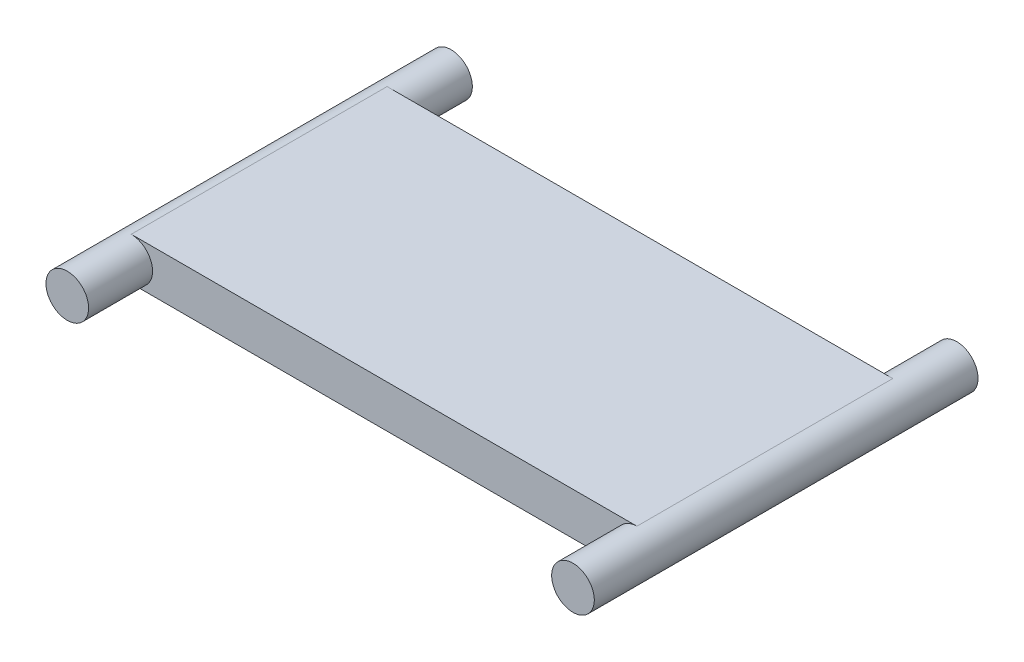
from build123d import *
from build123d.topology import SkipClean

# Parameters (mm, degrees)
BOSS_EXTRUDE1_DEPTH     = 9.525
SKETCH3_R               = 1.5875
BOSS_EXTRUDE3_DEPTH     = 4.7625
MIRROR2_COPY_1_SKETCH_R = 1.5875
MIRROR2_COPY_1_DEPTH    = 4.7625


with BuildPart() as part:
    # Sketch1 → Boss-Extrude1 (new body, symmetric)
    with BuildSketch(Plane.XY):
        with BuildLine():
            Line((-18.82775, 1.5875), (18.82775, 1.5875))
            ThreePointArc((18.82775, 1.5875), (20.41525, 0), (18.82775, -1.5875))
            Line((18.82775, -1.5875), (-18.82775, -1.5875))
            ThreePointArc((-18.82775, -1.5875), (-20.41525, 0), (-18.82775, 1.5875))
        make_face()
    extrude(amount=BOSS_EXTRUDE1_DEPTH, both=True)

    # Sketch3 → Boss-Extrude3 (add)
    with BuildSketch(Plane.XY.offset(9.525)):
        with Locations(Location((-18.82775, 0, 0), (0, 0, 270))):  # turned: the seam where the file's is
            Circle(SKETCH3_R)
    boss_extrude3 = extrude(amount=BOSS_EXTRUDE3_DEPTH)

    # Mirror1: Boss-Extrude3 across plane
    with SkipClean():  # keep this step's faces unmerged: merging them makes the solid invalid here
        add(boss_extrude3.mirror(Plane(origin=(0, 0, 0), x_dir=(0, 0, 1), z_dir=(1, 0, 0))))

    # Mirror2: Boss-Extrude3 across plane
    with SkipClean():  # keep this step's faces unmerged: merging them makes the solid invalid here
        add(boss_extrude3.mirror(Plane.XY))

    # Mirror2 copy 1 sketch → Mirror2 copy 1 (add)
    with BuildSketch(Plane(origin=(0, 0, -9.525), x_dir=(-1, 0, 0), z_dir=(0, 0, -1))):
        with Locations(Location((-18.82775, 0, 0), (0, 0, 270))):  # turned: the seam where the file's is
            Circle(MIRROR2_COPY_1_SKETCH_R)
    extrude(amount=MIRROR2_COPY_1_DEPTH)


solid = part.part
